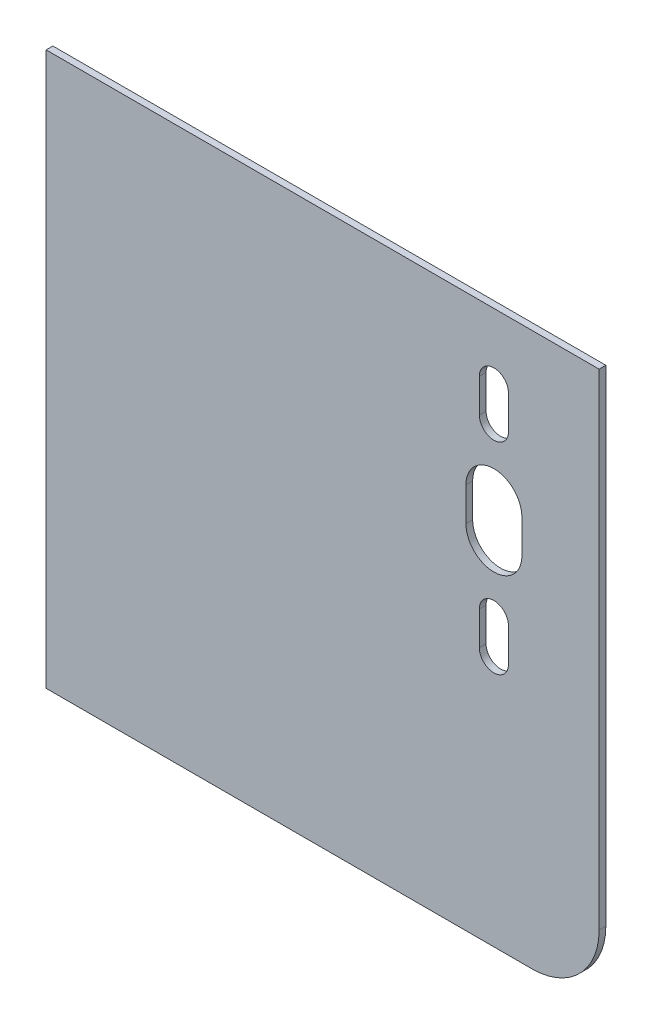
from build123d import *

# Parameters (mm, degrees)
ESQUISSE1_W             = 247
ESQUISSE1_H             = 247
ESQUISSE1_R             = 12.5
ESQUISSE1_R_2           = 6.5
BOSS_EXTRU_1_DEPTH      = 3
CONG_1_R                = 30
ENL_V_MAT_EXTRU_2_DEPTH = 10


with BuildPart() as part:
    # Esquisse1 → Boss.-Extru.1 (new body)
    with BuildSketch(Plane.XY):
        Rectangle(ESQUISSE1_W, ESQUISSE1_H)
        with Locations((76.5, 41.5)):
            Circle(ESQUISSE1_R, mode=Mode.SUBTRACT)
        with Locations((76.5, 86.5)):
            Circle(ESQUISSE1_R_2, mode=Mode.SUBTRACT)
        with Locations((76.5, -3.5)):
            Circle(ESQUISSE1_R_2, mode=Mode.SUBTRACT)
    extrude(amount=BOSS_EXTRU_1_DEPTH)

    # Congé1
    cong_1_edges = [part.edges().sort_by_distance(p)[0] for p in [
        (123.5, -123.5, 1.5),
    ]]
    fillet(cong_1_edges, radius=CONG_1_R)

    # Esquisse4 → Enlèv. mat.-Extru.2 (cut)
    with BuildSketch(Plane(origin=(0, 0, 0), x_dir=(-1, 0, 0), z_dir=(0, 0, -1))):
        with BuildLine():
            Line((-83, 79), (-83, 94))
            ThreePointArc((-83, 94), (-76.5, 100.5), (-70, 94))
            Line((-70, 94), (-70, 79))
            ThreePointArc((-70, 79), (-76.5, 72.5), (-83, 79))
        make_face()
        with BuildLine():
            Line((-83, -11), (-83, 4))
            ThreePointArc((-83, 4), (-76.5, 10.5), (-70, 4))
            Line((-70, 4), (-70, -11))
            ThreePointArc((-70, -11), (-76.5, -17.5), (-83, -11))
        make_face()
        with BuildLine():
            Line((-89, 34), (-89, 49))
            ThreePointArc((-89, 49), (-76.5, 61.5), (-64, 49))
            Line((-64, 49), (-64, 34))
            ThreePointArc((-64, 34), (-76.5, 21.5), (-89, 34))
        make_face()
    extrude(amount=-ENL_V_MAT_EXTRU_2_DEPTH, mode=Mode.SUBTRACT)


solid = part.part
